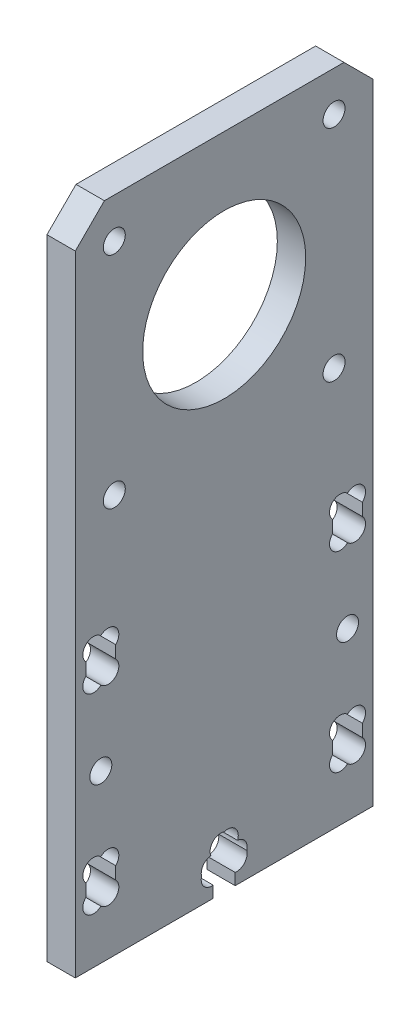
from build123d import *

# Parameters (mm, degrees)
CROQUIS1_W              = 42
CROQUIS1_H              = 92.91
CROQUIS1_R              = 11.5
CROQUIS1_R_2            = 1.55
SALIENTE_EXTRUIR1_DEPTH = 4
CROQUIS2_R              = 1.55
CROQUIS2_W              = 4.2
CROQUIS2_H              = 6
CORTAR_EXTRUIR1_DEPTH   = 5
CORTAR_EXTRUIR2_DEPTH   = 5
CORTAR_EXTRUIR3_DEPTH   = 5
CORTAR_EXTRUIR4_DEPTH   = 5
CHAFL_N1_SIZE           = 4.1


with BuildPart() as part:
    # Croquis1 → Saliente-Extruir1 (new body)
    with BuildSketch(Plane(origin=(0, 0, 0), x_dir=(0, 0, -1), z_dir=(1, 0, 0))):
        with Locations((21, 46.455)):
            Rectangle(CROQUIS1_W, CROQUIS1_H)
        with Locations((21, 71.76)):
            Circle(CROQUIS1_R, mode=Mode.SUBTRACT)
        with Locations((5.5, 87.26)):
            Circle(CROQUIS1_R_2, mode=Mode.SUBTRACT)
        with Locations((36.5, 87.26)):
            Circle(CROQUIS1_R_2, mode=Mode.SUBTRACT)
        with Locations((36.5, 56.26)):
            Circle(CROQUIS1_R_2, mode=Mode.SUBTRACT)
        with Locations((5.5, 56.26)):
            Circle(CROQUIS1_R_2, mode=Mode.SUBTRACT)
    extrude(amount=SALIENTE_EXTRUIR1_DEPTH)

    # Croquis2 → Cortar-Extruir1 (cut, through all)
    with BuildSketch(Plane(origin=(4, 0, 0), x_dir=(0, 0, -1), z_dir=(1, 0, 0))):
        with Locations((3.6, 23.5)):
            Circle(CROQUIS2_R)
        with Locations((38.4, 23.5)):
            Circle(CROQUIS2_R)
        with Locations((3.6, 37)):
            Rectangle(CROQUIS2_W, CROQUIS2_H)
        with Locations((3.6, 10)):
            Rectangle(CROQUIS2_W, CROQUIS2_H)
        with Locations((38.4, 10)):
            Rectangle(CROQUIS2_W, CROQUIS2_H)
        with Locations((38.4, 37)):
            Rectangle(CROQUIS2_W, CROQUIS2_H)
    extrude(amount=-CORTAR_EXTRUIR1_DEPTH, mode=Mode.SUBTRACT)

    # Croquis3 → Cortar-Extruir2 (cut, through all)
    with BuildSketch(Plane(origin=(4, 0, 0), x_dir=(0, 0, -1), z_dir=(1, 0, 0))):
        Polygon((19.45, 0), (19.45, 2.05), (18.2, 2.05), (18.2, 4.95), (19.45, 4.95), (19.45, 7), (22.55, 7), (22.55, 4.95), (23.8, 4.95), (23.8, 2.05), (22.55, 2.05), (22.55, 0), align=None)
    extrude(amount=-CORTAR_EXTRUIR2_DEPTH, mode=Mode.SUBTRACT)

    # Croquis4 → Cortar-Extruir3 (cut, through all)
    with BuildSketch(Plane(origin=(4, 0, 0), x_dir=(0, 0, -1), z_dir=(1, 0, 0))):
        with BuildLine():
            Line((5.7, 37.878679656), (5.7, 36.121320344))
            ThreePointArc((5.7, 36.121320344), (5.710503119, 34.010608171), (3.6, 33.979099854))
            ThreePointArc((3.6, 33.979099854), (1.489496881, 34.010608171), (1.5, 36.121320344))
            Line((1.5, 36.121320344), (1.5, 37.878679656))
            ThreePointArc((1.5, 37.878679656), (1.489496881, 39.989391829), (3.6, 40.020900146))
            ThreePointArc((3.6, 40.020900146), (5.710503119, 39.989391829), (5.7, 37.878679656))
        make_face()
        with BuildLine():
            Line((40.5, 36.121320344), (40.5, 37.878679656))
            ThreePointArc((40.5, 37.878679656), (40.510503119, 39.989391829), (38.4, 40.020900146))
            ThreePointArc((38.4, 40.020900146), (36.289496881, 39.989391829), (36.3, 37.878679656))
            Line((36.3, 37.878679656), (36.3, 36.121320344))
            ThreePointArc((36.3, 36.121320344), (36.289496881, 34.010608171), (38.4, 33.979099854))
            ThreePointArc((38.4, 33.979099854), (40.510503119, 34.010608171), (40.5, 36.121320344))
        make_face()
        with BuildLine():
            Line((36.3, 9.121320344), (36.3, 10.878679656))
            ThreePointArc((36.3, 10.878679656), (36.289496881, 12.989391829), (38.4, 13.020900146))
            ThreePointArc((38.4, 13.020900146), (40.510503119, 12.989391829), (40.5, 10.878679656))
            Line((40.5, 10.878679656), (40.5, 9.121320344))
            ThreePointArc((40.5, 9.121320344), (40.510503119, 7.010608171), (38.4, 6.979099854))
            ThreePointArc((38.4, 6.979099854), (36.289496881, 7.010608171), (36.3, 9.121320344))
        make_face()
        with BuildLine():
            Line((5.7, 9.121320344), (5.7, 10.878679656))
            ThreePointArc((5.7, 10.878679656), (5.710503119, 12.989391829), (3.6, 13.020900146))
            ThreePointArc((3.6, 13.020900146), (1.489496881, 12.989391829), (1.5, 10.878679656))
            Line((1.5, 10.878679656), (1.5, 9.121320344))
            ThreePointArc((1.5, 9.121320344), (1.489496881, 7.010608171), (3.6, 6.979099854))
            ThreePointArc((3.6, 6.979099854), (5.710503119, 7.010608171), (5.7, 9.121320344))
        make_face()
    extrude(amount=-CORTAR_EXTRUIR3_DEPTH, mode=Mode.SUBTRACT)

    # Croquis5 → Cortar-Extruir4 (cut, through all)
    with BuildSketch(Plane(origin=(4, 0, 0), x_dir=(0, 0, -1), z_dir=(1, 0, 0))):
        with BuildLine():
            Line((21.678679656, 2.05), (20.321320344, 2.05))
            ThreePointArc((20.321320344, 2.05), (18.510162011, 1.811909807), (17.812069651, 3.5))
            ThreePointArc((17.812069651, 3.5), (18.028132476, 4.744252385), (19.117836757, 5.382524838))
            ThreePointArc((19.117836757, 5.382524838), (19.424850602, 6.97423962), (21, 7.35727725))
            ThreePointArc((21, 7.35727725), (22.575149398, 6.97423962), (22.882163243, 5.382524838))
            ThreePointArc((22.882163243, 5.382524838), (23.971867524, 4.744252385), (24.187930349, 3.5))
            ThreePointArc((24.187930349, 3.5), (23.489837989, 1.811909807), (21.678679656, 2.05))
        make_face()
    extrude(amount=-CORTAR_EXTRUIR4_DEPTH, mode=Mode.SUBTRACT)

    # Chaflán1
    chafl_n1_edges = [part.edges().sort_by_distance(p)[0] for p in [
        (2, 92.91, 0),
        (2, 92.91, -42),
    ]]
    chamfer(chafl_n1_edges, length=CHAFL_N1_SIZE)


solid = part.part
